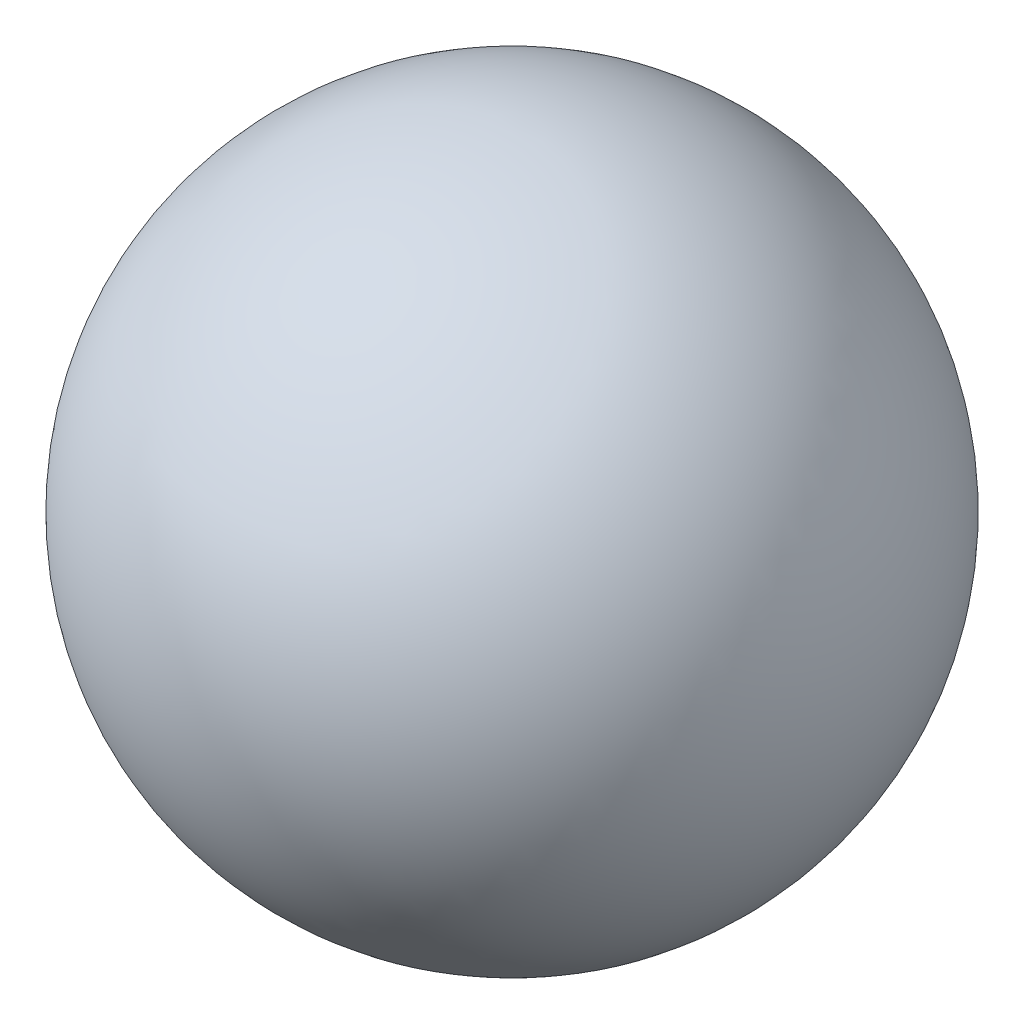
from build123d import *


with BuildPart() as part:
    # Sketch1 → Revolve1 (revolve)
    with BuildSketch(Plane.XY):
        with BuildLine():
            Line((0, 1.25), (0, -1.25))
            ThreePointArc((0, -1.25), (1.25, 0), (0, 1.25))
        make_face()
    revolve(axis=Axis((0, 1.25, 0), (0, -1, 0)))


solid = part.part
